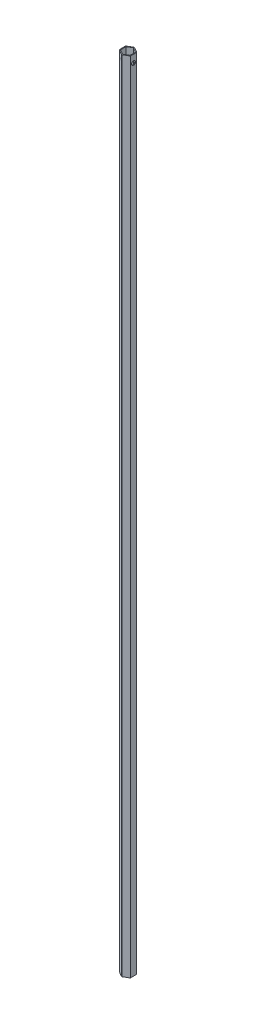
from build123d import *

# Parameters (mm, degrees)
BOSS_EXTRUDE1_DEPTH         = 1322.07
FILLET1_R                   = 1.27
BOSS_EXTRUDE2_DEPTH         = 2.54
F_1_4_0_25_DIAMETER_HOLE1_D = 6.35
F_1_4_CLEARANCE_HOLE1_D     = 6.7564


with BuildPart() as part:
    # Sketch1 → Boss-Extrude1 (new body)
    with BuildSketch(Plane(origin=(0, 0, 0), x_dir=(1, 0, 0), z_dir=(0, 1, 0))):
        Polygon((-9.225470009, 5.284705426), (-9.189424155, -5.347138677), (0.036045854, -10.631844103), (9.225470009, -5.284705426), (9.189424155, 5.347138677), (-0.036045854, 10.631844103), align=None)
        Polygon((-7.98301547, 4.502962617), (-7.891187754, -4.662012887), (0.091827716, -9.164975505), (7.98301547, -4.502962617), (7.891187754, 4.662012887), (-0.091827716, 9.164975505), align=None, mode=Mode.SUBTRACT)
    extrude(amount=BOSS_EXTRUDE1_DEPTH)

    # Fillet1
    fillet1_edges = [part.edges().sort_by_distance(p)[0] for p in [
        (-0.036045854, 661.035, -10.631844103),
        (9.189424155, 661.035, -5.347138677),
        (0.036045854, 661.035, 10.631844103),
        (-9.189424155, 661.035, 5.347138677),
        (-9.225470009, 661.035, -5.284705426),
        (7.98301547, 661.035, 4.502962617),
    ]]
    fillet(fillet1_edges, radius=FILLET1_R)

    # Sketch3 → Boss-Extrude2 (add)
    with BuildSketch(Plane.XZ):
        with BuildLine():
            Line((0.600193457, -10.26738166), (8.553184844, -5.71160112))
            ThreePointArc((8.553184844, -5.71160112), (9.019610446, -5.24832754), (9.191910076, -4.613908049))
            Line((9.191910076, -4.613908049), (9.225470009, 5.284705426))
            Line((9.225470009, 5.284705426), (0.669799244, 10.263075918))
            ThreePointArc((0.669799244, 10.263075918), (0.035379754, 10.435375548), (-0.600193457, 10.26738166))
            Line((-0.600193457, 10.26738166), (-8.553184844, 5.71160112))
            ThreePointArc((-8.553184844, 5.71160112), (-9.019610446, 5.24832754), (-9.191910076, 4.613908049))
            Line((-9.191910076, 4.613908049), (-9.222984088, -4.551474798))
            ThreePointArc((-9.222984088, -4.551474798), (-9.0549902, -5.187048009), (-8.591716619, -5.653473611))
            Line((-8.591716619, -5.653473611), (-0.669799244, -10.263075918))
            ThreePointArc((-0.669799244, -10.263075918), (-0.035379754, -10.435375548), (0.600193457, -10.26738166))
        make_face()
    extrude(amount=BOSS_EXTRUDE2_DEPTH)

    # 1/4 (0.25) Diameter Hole1 (through all)
    with Locations(Plane(origin=(0, -2.54, 0), x_dir=(-1, 0, 0), z_dir=(0, -1, 0))):
        with Locations((0, 0)):
            Hole(F_1_4_0_25_DIAMETER_HOLE1_D / 2)

    # 1/4 Clearance Hole1 (through all)
    with Locations(Plane(origin=(9.207563136, 0, 0.003013921), x_dir=(-0.003390348, 0, -0.999994253), z_dir=(0.999994253, 0, -0.003390348))):
        with Locations((0, 1309.37)):
            Hole(F_1_4_CLEARANCE_HOLE1_D / 2)


solid = part.part
